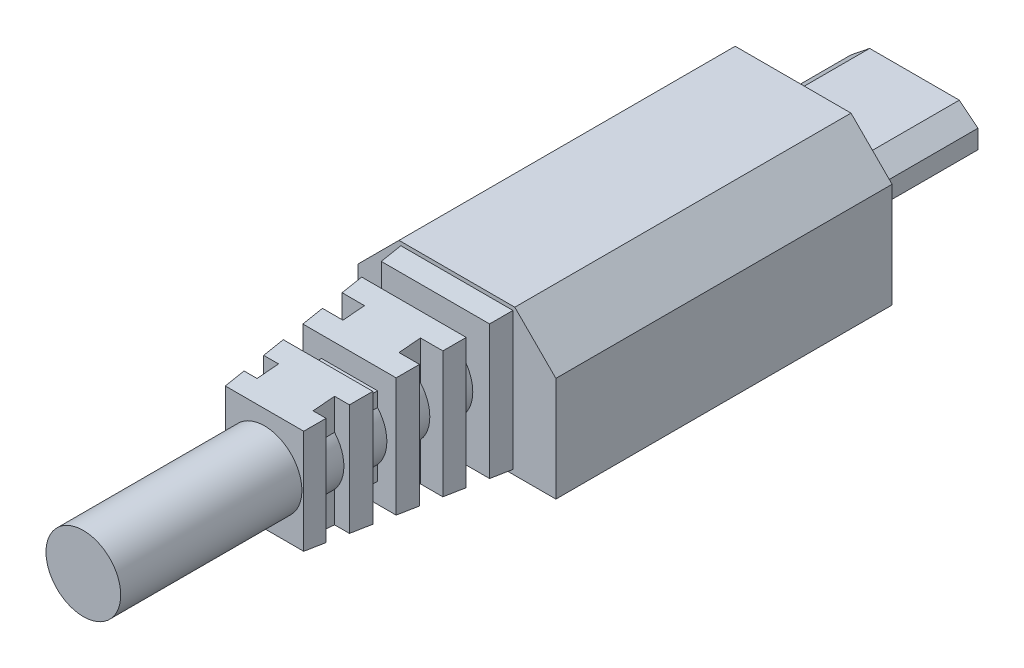
from build123d import *

# Parameters (mm, degrees)
SKETCH1_W           = 3.7
SKETCH1_H           = 0.65
BOSS_EXTRUDE1_DEPTH = 6.5
SKETCH2_W           = 3.7
SKETCH2_H           = 0.65
BOSS_EXTRUDE2_DEPTH = 18
SKETCH5_W           = 6
SKETCH5_H           = 7.371976581
BOSS_EXTRUDE4_DEPTH = 10.3
BOSS_EXTRUDE4_TAPER = 5
SKETCH7_W           = 2.169554373
SKETCH7_H           = 1.15
CUT_EXTRUDE1_DEPTH  = 10.3
SKETCH9_W           = 1.15
SKETCH9_H           = 1.6
CUT_EXTRUDE2_DEPTH  = 10.3
SKETCH3_R           = 2
BOSS_EXTRUDE3_DEPTH = 20


with BuildPart() as part:
    # Sketch1 → Boss-Extrude1 (new body)
    with BuildSketch(Plane.XY):
        Polygon((1, 1.8), (0, 1), (0, 0), (6.8, 0), (6.8, 1), (5.8, 1.8), align=None)
        with Locations((3.4, 0.525)):
            Rectangle(SKETCH1_W, SKETCH1_H, mode=Mode.SUBTRACT)
    extrude(amount=BOSS_EXTRUDE1_DEPTH)

    # Sketch2 → Boss-Extrude2 (add)
    with BuildSketch(Plane.XY.offset(6.5)):
        Polygon((6.5, 4.8), (0.3, 4.8), (-1.9, 2.6), (-1.9, -3), (8.7, -3), (8.7, 2.6), align=None)
        Polygon((5.8, 1.8), (6.8, 1), (6.8, 0), (0, 0), (0, 1), (1, 1.8), align=None, mode=Mode.SUBTRACT)
        Polygon((6.8, 0), (6.8, 1), (5.8, 1.8), (1, 1.8), (0, 1), (0, 0), align=None)
        with Locations((3.4, 0.525)):
            Rectangle(SKETCH2_W, SKETCH2_H, mode=Mode.SUBTRACT)
        with Locations((3.4, 0.525)):
            Rectangle(SKETCH2_W, SKETCH2_H)
    extrude(amount=BOSS_EXTRUDE2_DEPTH)

    # Sketch5 → Boss-Extrude4 (add)
    with BuildSketch(Plane.XY.offset(24.5)):
        with Locations((3.4, 0.91401171)):
            Rectangle(SKETCH5_W, SKETCH5_H)
    extrude(amount=BOSS_EXTRUDE4_DEPTH, taper=BOSS_EXTRUDE4_TAPER)

    # Sketch7 → Cut-Extrude1 (cut)
    with BuildSketch(Plane(origin=(0, 4.8, 0), x_dir=(1, 0, 0), z_dir=(0, 1, 0))):
        Polygon((1.9, -25.65), (0.3, -25.65), (-0.269554373, -25.65), (-0.269554373, -26.8), (1.9, -26.8), align=None)
        with Locations((0.815222814, -28.525)):
            Rectangle(SKETCH7_W, SKETCH7_H)
        with Locations((0.815222814, -30.825)):
            Rectangle(SKETCH7_W, SKETCH7_H)
        with Locations((0.815222814, -33.125)):
            Rectangle(SKETCH7_W, SKETCH7_H)
        with Locations((5.984777187, -26.225)):
            Rectangle(SKETCH7_W, SKETCH7_H)
        with Locations((5.984777187, -28.525)):
            Rectangle(SKETCH7_W, SKETCH7_H)
        with Locations((5.984777187, -30.825)):
            Rectangle(SKETCH7_W, SKETCH7_H)
        with Locations((5.984777187, -33.125)):
            Rectangle(SKETCH7_W, SKETCH7_H)
    extrude(amount=-CUT_EXTRUDE1_DEPTH, mode=Mode.SUBTRACT)

    # Sketch9 → Cut-Extrude2 (cut)
    with BuildSketch(Plane(origin=(8.7, 0, 0), x_dir=(0, 0, -1), z_dir=(1, 0, 0))):
        with Locations((-26.225, 3.8)):
            Rectangle(SKETCH9_W, SKETCH9_H)
        with Locations((-30.825, 3.8)):
            Rectangle(SKETCH9_W, SKETCH9_H)
        with Locations((-26.225, -2)):
            Rectangle(SKETCH9_W, SKETCH9_H)
        with Locations((-30.825, -2)):
            Rectangle(SKETCH9_W, SKETCH9_H)
    extrude(amount=-CUT_EXTRUDE2_DEPTH, mode=Mode.SUBTRACT)

    # Sketch3 → Boss-Extrude3 (add)
    with BuildSketch(Plane.XY.offset(24.5)):
        with Locations(Location((3.4, 0.9, 0), (0, 0, 180))):  # turned: the seam where the file's is
            Circle(SKETCH3_R)
    extrude(amount=BOSS_EXTRUDE3_DEPTH)


solid = part.part
